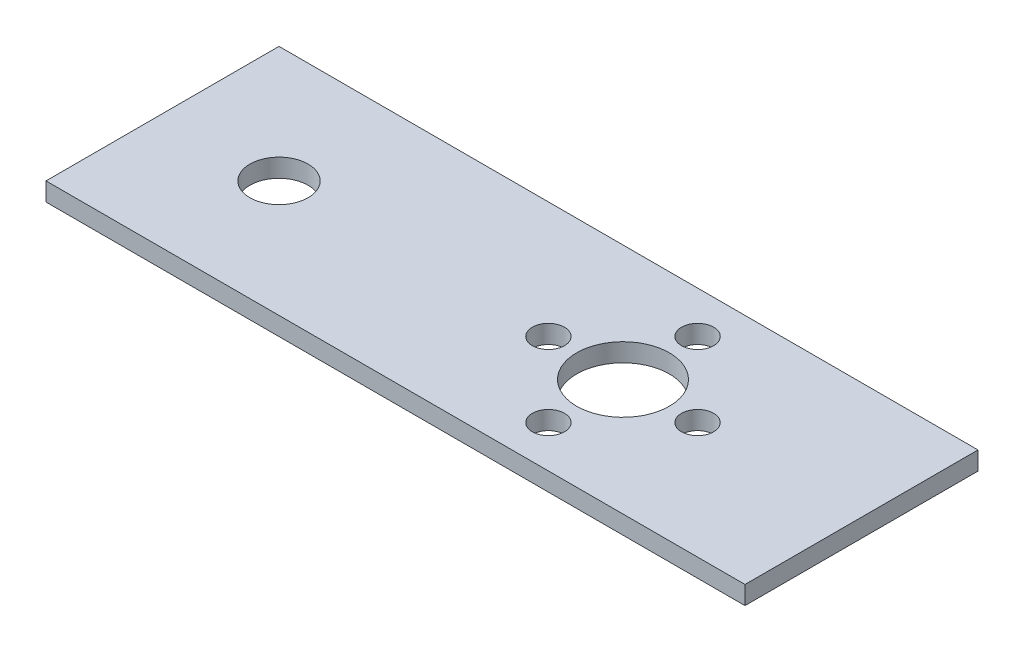
from build123d import *

# Parameters (mm, degrees)
SKETCH1_W           = 76.2
SKETCH1_H           = 25.4
SKETCH1_R           = 5.05
SKETCH1_R_2         = 1.75
SKETCH1_R_3         = 3.175
BOSS_EXTRUDE1_DEPTH = 2


with BuildPart() as part:
    # Sketch1 → Boss-Extrude1 (new body)
    with BuildSketch(Plane(origin=(0, 0, 0), x_dir=(1, 0, 0), z_dir=(0, 1, 0))):
        with Locations((0.3, 0)):
            Rectangle(SKETCH1_W, SKETCH1_H)
        with Locations((12.4, 0)):
            Circle(SKETCH1_R, mode=Mode.SUBTRACT)
        with Locations((12.4, 8.13)):
            Circle(SKETCH1_R_2, mode=Mode.SUBTRACT)
        with Locations((20.53, 0)):
            Circle(SKETCH1_R_2, mode=Mode.SUBTRACT)
        with Locations((12.4, -8.13)):
            Circle(SKETCH1_R_2, mode=Mode.SUBTRACT)
        with Locations((4.27, 0)):
            Circle(SKETCH1_R_2, mode=Mode.SUBTRACT)
        with Locations((-25.1, 0)):
            Circle(SKETCH1_R_3, mode=Mode.SUBTRACT)
    extrude(amount=BOSS_EXTRUDE1_DEPTH)


solid = part.part
